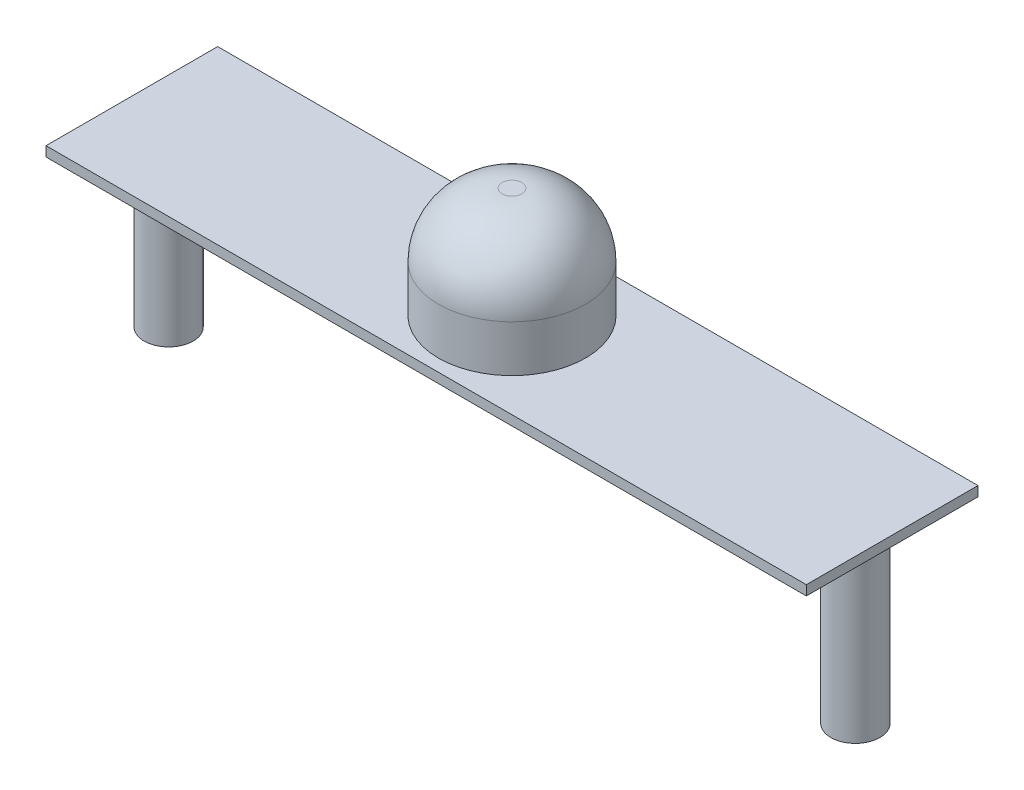
from build123d import *

# Parameters (mm, degrees)
SKETCH1_W           = 98.425
SKETCH1_H           = 22.225
BOSS_EXTRUDE1_DEPTH = 1.27
SKETCH2_R           = 9.525
BOSS_EXTRUDE2_DEPTH = 14.2875
FILLET3_R           = 8.255
SKETCH3_R           = 3.175
BOSS_EXTRUDE3_DEPTH = 22.225


with BuildPart() as part:
    # Sketch1 → Boss-Extrude1 (new body)
    with BuildSketch(Plane(origin=(0, 0, 0), x_dir=(1, 0, 0), z_dir=(0, 1, 0))):
        Rectangle(SKETCH1_W, SKETCH1_H)
    extrude(amount=BOSS_EXTRUDE1_DEPTH)

    # Sketch2 → Boss-Extrude2 (add)
    with BuildSketch(Plane(origin=(0, 1.27, 0), x_dir=(1, 0, 0), z_dir=(0, 1, 0))):
        Circle(SKETCH2_R)
    extrude(amount=BOSS_EXTRUDE2_DEPTH)

    # Fillet3
    fillet3_edges = [part.edges().sort_by_distance(p)[0] for p in [
        (-9.525, 15.5575, 0),
    ]]
    fillet(fillet3_edges, radius=FILLET3_R)

    # Sketch3 → Boss-Extrude3 (add)
    with BuildSketch(Plane.XZ):
        with Locations((-44.45, 0)):
            Circle(SKETCH3_R)
        with Locations((44.45, 0)):
            Circle(SKETCH3_R)
    extrude(amount=BOSS_EXTRUDE3_DEPTH)


solid = part.part
